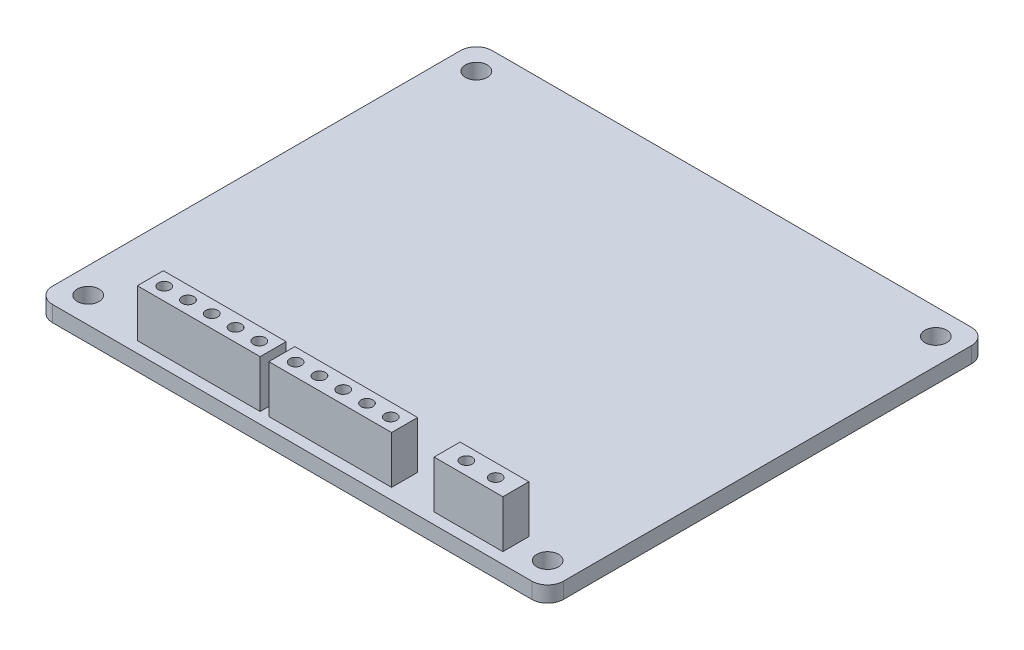
from build123d import *

# Parameters (mm, degrees)
SKETCH1_W           = 64.5
SKETCH1_H           = 55.5
BOSS_EXTRUDE1_DEPTH = 2
FILLET1_R           = 2
SKETCH2_R           = 1.375
CUT_EXTRUDE1_DEPTH  = 2
SKETCH3_W           = 15.5
SKETCH3_H           = 3.282744178
SKETCH3_W_2         = 8.679035978
BOSS_EXTRUDE2_DEPTH = 6
SKETCH4_R           = 0.75
CUT_EXTRUDE2_DEPTH  = 3
LPATTERN1_COUNT     = 3
LPATTERN1_PITCH     = 3
LPATTERN1_COL_COUNT = 3
LPATTERN1_COL_PITCH = 3
SKETCH5_R           = 0.75
CUT_EXTRUDE3_DEPTH  = 3
LPATTERN2_COUNT     = 3
LPATTERN2_PITCH     = 3
LPATTERN2_COL_COUNT = 3
LPATTERN2_COL_PITCH = 3
SKETCH6_R           = 0.75
CUT_EXTRUDE4_DEPTH  = 3
LPATTERN3_COUNT     = 2
LPATTERN3_PITCH     = 3.7


with BuildPart() as part:
    # Sketch1 → Boss-Extrude1 (new body)
    with BuildSketch(Plane(origin=(0, 0, 0), x_dir=(1, 0, 0), z_dir=(0, 1, 0))):
        Rectangle(SKETCH1_W, SKETCH1_H)
    extrude(amount=BOSS_EXTRUDE1_DEPTH)

    # Fillet1
    fillet1_edges = [part.edges().sort_by_distance(p)[0] for p in [
        (32.25, 1, 27.75),
        (-32.25, 1, 27.75),
        (-32.25, 1, -27.75),
        (32.25, 1, -27.75),
    ]]
    fillet(fillet1_edges, radius=FILLET1_R)

    # Sketch2 → Cut-Extrude1 (cut)
    with BuildSketch(Plane(origin=(0, 2, 0), x_dir=(1, 0, 0), z_dir=(0, 1, 0))):
        with Locations((-29, 24.5)):
            Circle(SKETCH2_R)
        with Locations((29, 24.5)):
            Circle(SKETCH2_R)
        with Locations((29, -24.5)):
            Circle(SKETCH2_R)
        with Locations((-29, -24.5)):
            Circle(SKETCH2_R)
    extrude(amount=-CUT_EXTRUDE1_DEPTH, mode=Mode.SUBTRACT)

    # Sketch3 → Boss-Extrude2 (add)
    with BuildSketch(Plane(origin=(0, 2, 0), x_dir=(1, 0, 0), z_dir=(0, 1, 0))):
        with Locations((-13.190464122, -24.709786803)):
            Rectangle(SKETCH3_W, SKETCH3_H)
        with Locations((3.403133163, -24.709786803)):
            Rectangle(SKETCH3_W, SKETCH3_H)
        with Locations((20.858312779, -24.709786803)):
            Rectangle(SKETCH3_W_2, SKETCH3_H)
    extrude(amount=BOSS_EXTRUDE2_DEPTH)

    # Sketch4 → Cut-Extrude2 (cut)
    with BuildSketch(Plane(origin=(0, 8, 0), x_dir=(1, 0, 0), z_dir=(0, 1, 0))):
        with Locations((-13.190464122, -24.709786803)):
            Circle(SKETCH4_R)
    cut_extrude2 = extrude(amount=-CUT_EXTRUDE2_DEPTH, mode=Mode.SUBTRACT)

    # LPattern1: Cut-Extrude2 ×3
    with Locations(*[(-i * LPATTERN1_PITCH, 0, 0) for i in range(1, LPATTERN1_COUNT)]):
        add(cut_extrude2, mode=Mode.SUBTRACT)

    # LPattern1 col: Cut-Extrude2 ×3
    with Locations(*[(i * LPATTERN1_COL_PITCH, 0, 0) for i in range(1, LPATTERN1_COL_COUNT)]):
        add(cut_extrude2, mode=Mode.SUBTRACT)

    # Sketch5 → Cut-Extrude3 (cut)
    with BuildSketch(Plane(origin=(0, 8, 0), x_dir=(1, 0, 0), z_dir=(0, 1, 0))):
        with Locations((3.403133163, -24.709786803)):
            Circle(SKETCH5_R)
    cut_extrude3 = extrude(amount=-CUT_EXTRUDE3_DEPTH, mode=Mode.SUBTRACT)

    # LPattern2: Cut-Extrude3 ×3
    with Locations(*[(-i * LPATTERN2_PITCH, 0, 0) for i in range(1, LPATTERN2_COUNT)]):
        add(cut_extrude3, mode=Mode.SUBTRACT)

    # LPattern2 col: Cut-Extrude3 ×3
    with Locations(*[(i * LPATTERN2_COL_PITCH, 0, 0) for i in range(1, LPATTERN2_COL_COUNT)]):
        add(cut_extrude3, mode=Mode.SUBTRACT)

    # Sketch6 → Cut-Extrude4 (cut)
    with BuildSketch(Plane(origin=(0, 8, 0), x_dir=(1, 0, 0), z_dir=(0, 1, 0))):
        with Locations((18.945697915, -24.709786803)):
            Circle(SKETCH6_R)
    cut_extrude4 = extrude(amount=-CUT_EXTRUDE4_DEPTH, mode=Mode.SUBTRACT)

    # LPattern3: Cut-Extrude4 ×2
    with Locations(*[(i * LPATTERN3_PITCH, 0, 0) for i in range(1, LPATTERN3_COUNT)]):
        add(cut_extrude4, mode=Mode.SUBTRACT)


solid = part.part
